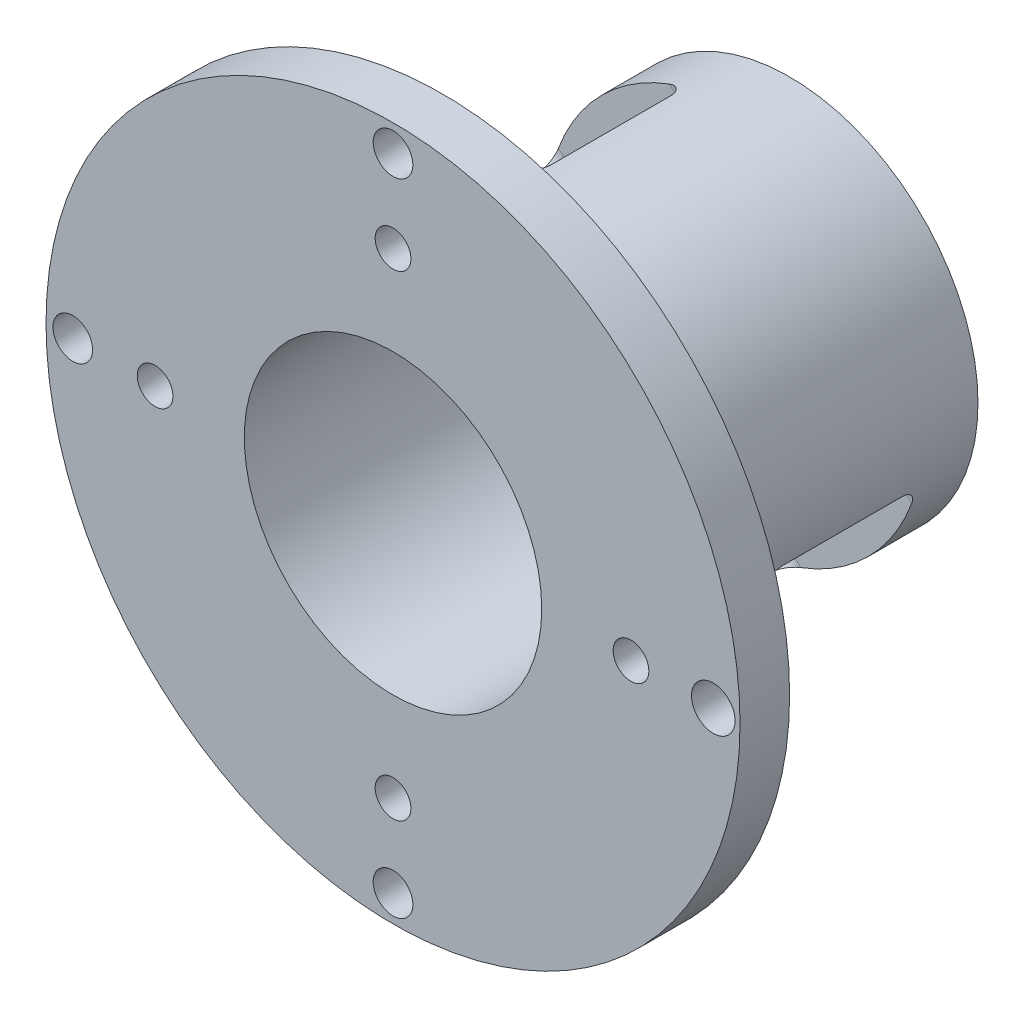
from build123d import *

# Parameters (mm, degrees)
SKETCH_1_R               = 35
SKETCH_1_R_2             = 4
EXTRUDE_1_DEPTH          = 40
SKETCH_3_R               = 35
SKETCH_3_R_2             = 19
CUT_EXTRUDE_1_DEPTH      = 35
SKETCH_4_R               = 15
CUT_EXTRUDE_2_DEPTH      = 33.5
SKETCH_6_R               = 1.8
SKETCH_6_R_2             = 2
SKETCH_6_R_3             = 2.2
CUT_EXTRUDE_3_DEPTH      = 41
SKETCH_7_R               = 1.5
SKETCH_7_R_2             = 1.75
CUT_EXTRUDE_4_DEPTH      = 41
CUT_EXTRUDE_5_DEPTH      = 50.497474683
CUT_EXTRUDE_5_DEPTH_BACK = 50.497474683
SKETCH_12_R              = 1.5
SKETCH_12_R_2            = 4
CUT_EXTRUDE_6_DEPTH      = 3


with BuildPart() as part:
    # 草图1 → 凸台-拉伸1 (new body)
    with BuildSketch(Plane.XY):
        Circle(SKETCH_1_R)
        Circle(SKETCH_1_R_2, mode=Mode.SUBTRACT)
    extrude(amount=EXTRUDE_1_DEPTH)

    # 草图3 → 切除-拉伸1 (cut)
    with BuildSketch(Plane.XY):
        Circle(SKETCH_3_R)
        Circle(SKETCH_3_R_2, mode=Mode.SUBTRACT)
    extrude(amount=CUT_EXTRUDE_1_DEPTH, mode=Mode.SUBTRACT)

    # 草图4 → 切除-拉伸2 (cut)
    with BuildSketch(Plane.XY.offset(40)):
        Circle(SKETCH_4_R)
    extrude(amount=-CUT_EXTRUDE_2_DEPTH, mode=Mode.SUBTRACT)

    # 草图6 → 切除-拉伸3 (cut, through all)
    with BuildSketch(Plane.XY):
        with Locations((-24, 0)):
            Circle(SKETCH_6_R)
        with Locations((0, -24)):
            Circle(SKETCH_6_R)
        with Locations((24, 0)):
            Circle(SKETCH_6_R)
        with Locations((0, 24)):
            Circle(SKETCH_6_R)
        with Locations((-32.3, 0)):
            Circle(SKETCH_6_R_2)
        with Locations((32.3, 0)):
            Circle(SKETCH_6_R_3)
        with Locations((0, 32.3)):
            Circle(SKETCH_6_R_2)
        with Locations((0, -32.3)):
            Circle(SKETCH_6_R_2)
    extrude(amount=CUT_EXTRUDE_3_DEPTH, mode=Mode.SUBTRACT)

    # 草图7 → 切除-拉伸4 (cut, through all)
    with BuildSketch(Plane(origin=(0, 0, 0), x_dir=(-1, 0, 0), z_dir=(0, 0, -1))):
        with Locations((-9.5, 0)):
            Circle(SKETCH_7_R)
        with Locations((0, 8)):
            Circle(SKETCH_7_R)
        with Locations((9.5, 0)):
            Circle(SKETCH_7_R)
        with Locations((0, -8)):
            Circle(SKETCH_7_R)
        with Locations((-8.131727984, -8.131727984)):
            Circle(SKETCH_7_R_2)
        with Locations((-8.131727984, 8.131727984)):
            Circle(SKETCH_7_R_2)
        with Locations((8.131727984, 8.131727984)):
            Circle(SKETCH_7_R_2)
        with Locations((8.131727984, -8.131727984)):
            Circle(SKETCH_7_R_2)
    extrude(amount=-CUT_EXTRUDE_4_DEPTH, mode=Mode.SUBTRACT)

    # 草图9 → 切除-拉伸5 (cut, two sides)
    with BuildSketch(Plane(origin=(0, 0, 0), x_dir=(0.707106781, 0.707106781, 0), z_dir=(0.707106781, -0.707106781, 0))) as cut_extrude_5_sk:
        with BuildLine():
            Line((-7.91330988, 20.5), (7.91330988, 20.5))
            ThreePointArc((7.91330988, 20.5), (8.973970052, 20.060660172), (9.41330988, 19))
            Line((9.41330988, 19), (9.41330988, 7))
            ThreePointArc((9.41330988, 7), (8.973970052, 5.939339828), (7.91330988, 5.5))
            Line((7.91330988, 5.5), (-7.91330988, 5.5))
            ThreePointArc((-7.91330988, 5.5), (-8.973970052, 5.939339828), (-9.41330988, 7))
            Line((-9.41330988, 7), (-9.41330988, 19))
            ThreePointArc((-9.41330988, 19), (-8.973970052, 20.060660172), (-7.91330988, 20.5))
        make_face()
    extrude(amount=CUT_EXTRUDE_5_DEPTH, mode=Mode.SUBTRACT)
    extrude(cut_extrude_5_sk.sketch, amount=-CUT_EXTRUDE_5_DEPTH_BACK, mode=Mode.SUBTRACT)

    # 草图12 → 切除-拉伸6 (cut)
    with BuildSketch(Plane(origin=(0, 0, 0), x_dir=(-1, 0, 0), z_dir=(0, 0, -1))):
        with BuildLine():
            ThreePointArc((10, -4), (5.757359313, -5.757359313), (4, -10))
            Line((4, -10), (4, -13))
            Line((4, -13), (0, -13))
            Line((0, -13), (-4, -13))
            Line((-4, -13), (-4, -10))
            ThreePointArc((-4, -10), (-5.757359313, -5.757359313), (-10, -4))
            Line((-10, -4), (-13, -4))
            Line((-13, -4), (-13, 0))
            Line((-13, 0), (-13, 4))
            Line((-13, 4), (-10, 4))
            ThreePointArc((-10, 4), (-5.757359313, 5.757359313), (-4, 10))
            Line((-4, 10), (-4, 13))
            Line((-4, 13), (0, 13))
            Line((0, 13), (4, 13))
            Line((4, 13), (4, 10))
            ThreePointArc((4, 10), (5.757359313, 5.757359313), (10, 4))
            Line((10, 4), (13, 4))
            Line((13, 4), (13, 0))
            Line((13, 0), (13, -4))
            Line((13, -4), (10, -4))
        make_face()
        with Locations((9.5, 0)):
            Circle(SKETCH_12_R, mode=Mode.SUBTRACT)
        with Locations((-9.5, 0)):
            Circle(SKETCH_12_R, mode=Mode.SUBTRACT)
        Circle(SKETCH_12_R_2, mode=Mode.SUBTRACT)
        with Locations((0, -8)):
            Circle(SKETCH_12_R, mode=Mode.SUBTRACT)
        with Locations((0, 8)):
            Circle(SKETCH_12_R, mode=Mode.SUBTRACT)
    extrude(amount=-CUT_EXTRUDE_6_DEPTH, mode=Mode.SUBTRACT)


solid = part.part
